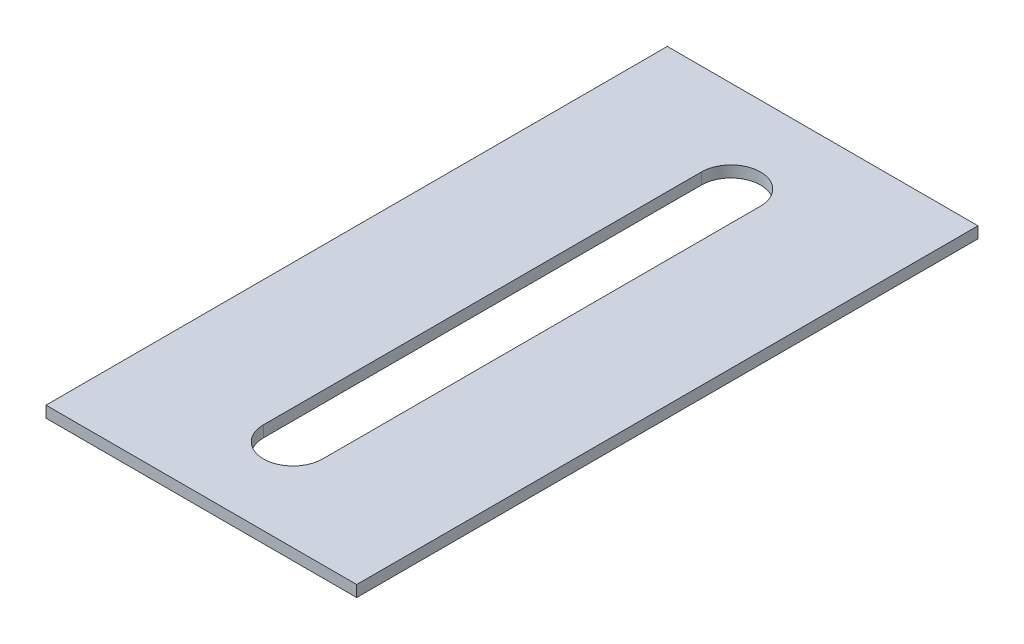
from build123d import *

# Parameters (mm, degrees)
BOSS_EXTRUDE1_DEPTH      = 0.9125
BOSS_EXTRUDE1_DEPTH_BACK = 0.9125
SKETCH1_W                = 50
SKETCH1_H                = 100


with BuildPart() as part:
    # Sketch1 → Boss-Extrude1 (new, two sides: drawn at the far end of the back side and taken through both)
    with BuildSketch(Plane(origin=(0, 0, 0), x_dir=(1, 0, 0), z_dir=(0, 1, 0)).offset(-BOSS_EXTRUDE1_DEPTH_BACK)):
        Rectangle(SKETCH1_W, SKETCH1_H)
        with BuildLine():
            Line((4.7625, 35.2375), (4.7625, -35.2375))
            ThreePointArc((4.7625, -35.2375), (0, -40), (-4.7625, -35.2375))
            Line((-4.7625, -35.2375), (-4.7625, 35.2375))
            ThreePointArc((-4.7625, 35.2375), (0, 40), (4.7625, 35.2375))
        make_face(mode=Mode.SUBTRACT)
    extrude(amount=BOSS_EXTRUDE1_DEPTH + BOSS_EXTRUDE1_DEPTH_BACK)


solid = part.part
